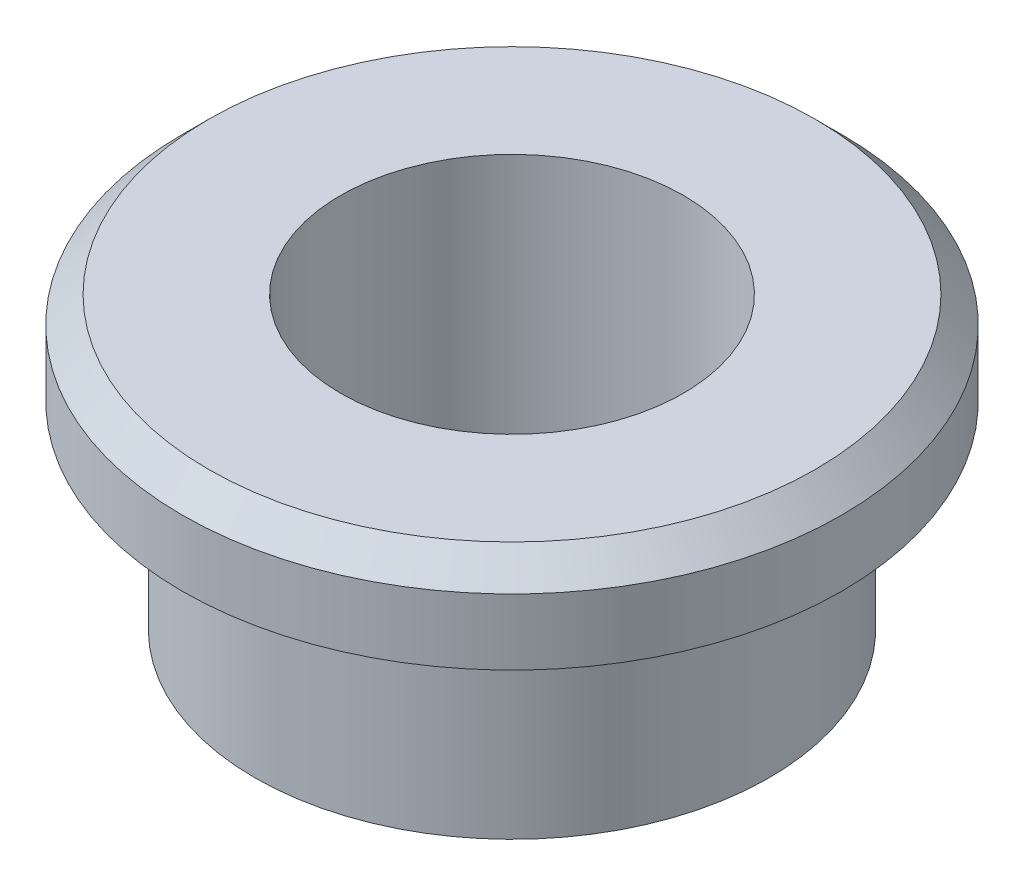
from build123d import *


with BuildPart() as part:
    # Sketch1 → Revolve1 (revolve)
    with BuildSketch(Plane.XY):
        Polygon((2.6, 4.4), (2.6, 0), (3.9, 0), (3.9, 3), (5, 3), (5, 4), (4.6, 4.4), align=None)
    revolve(axis=Axis((0, 9.791147956, 0), (0, -1, 0)))


solid = part.part
